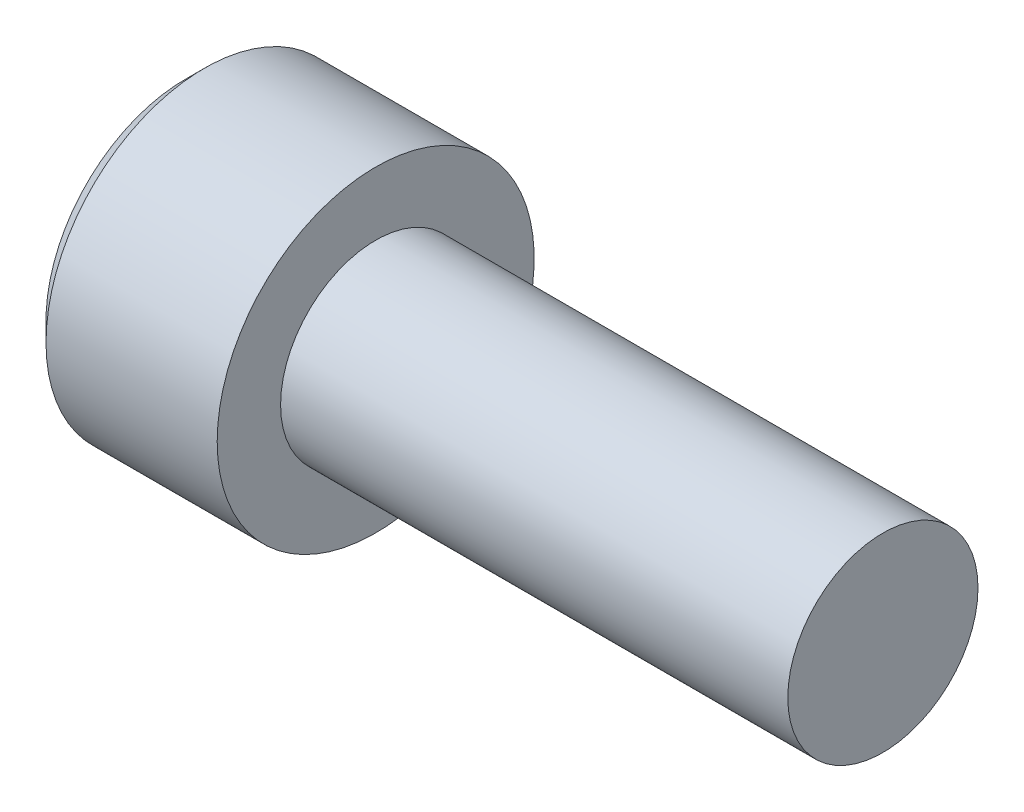
from build123d import *

# Parameters (mm, degrees)
CUT_EXTRUDE1_DEPTH = 3
CHAMFER1_SIZE      = 0.6


with BuildPart() as part:
    # Sketch1 → Revolve1 (revolve)
    with BuildSketch(Plane.XY):
        Polygon((0, 3), (16, 3), (16, 0), (-6, 0), (-6, 5), (0, 5), align=None)
    revolve(axis=Axis((-6, 0, 0), (1, 0, 0)))

    # Sketch2 → Cut-Revolve1 (revolve, cut)
    with BuildSketch(Plane.XY):
        Polygon((-1.497848452, 0), (-3, 2.5), (-6, 2.5), (-6, 0), align=None)
    revolve(axis=Axis((-6, 0, 0), (1, 0, 0)), mode=Mode.SUBTRACT)

    # Sketch3 → Cut-Extrude1 (cut)
    with BuildSketch(Plane.ZY.offset(6)):
        Polygon((2.5, 1.443375673), (0, 2.886751346), (-2.5, 1.443375673), (-2.5, -1.443375673), (0, -2.886751346), (2.5, -1.443375673), align=None)
    extrude(amount=-CUT_EXTRUDE1_DEPTH, mode=Mode.SUBTRACT)

    # Chamfer1
    chamfer1_edges = [part.edges().sort_by_distance(p)[0] for p in [
        (-6, -5, 0),
    ]]
    chamfer(chamfer1_edges, length=CHAMFER1_SIZE)


solid = part.part
